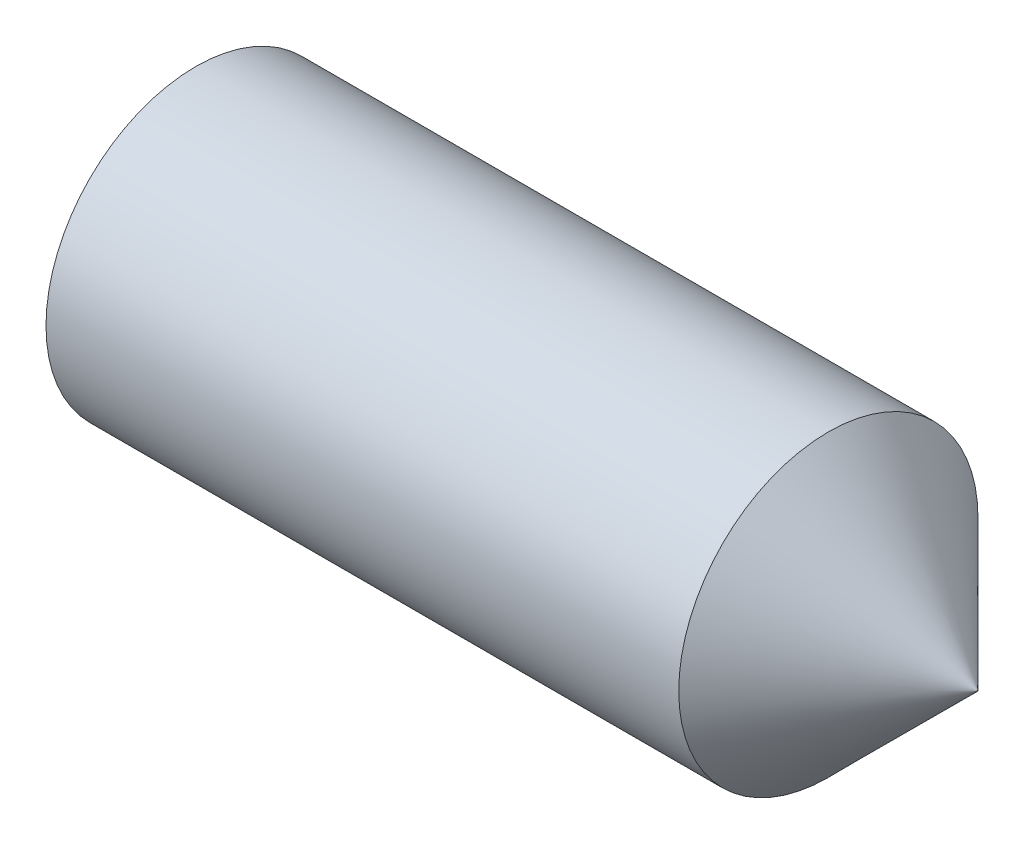
from build123d import *

# Parameters (mm, degrees)
HEX_2_DEPTH = 2.1


with BuildPart() as part:
    # BodySke → BaseBody (revolve)
    with BuildSketch(Plane.XY):
        Polygon((0, 0), (0, 1.2195), (0.161946751, 1.5), (6.505, 1.5), (8, 0.005), (8, 0), align=None)
    revolve(axis=Axis((-12.7, 0, 0), (1, 0, 0)))

    # Sketch2 → Hex 2 (cut)
    with BuildSketch(Plane.ZY):
        Polygon((0.433012702, 0.75), (-0.433012702, 0.75), (-0.866025404, 0), (-0.433012702, -0.75), (0.433012702, -0.75), (0.866025404, 0), align=None)
    extrude(amount=-HEX_2_DEPTH, mode=Mode.SUBTRACT)


solid = part.part
